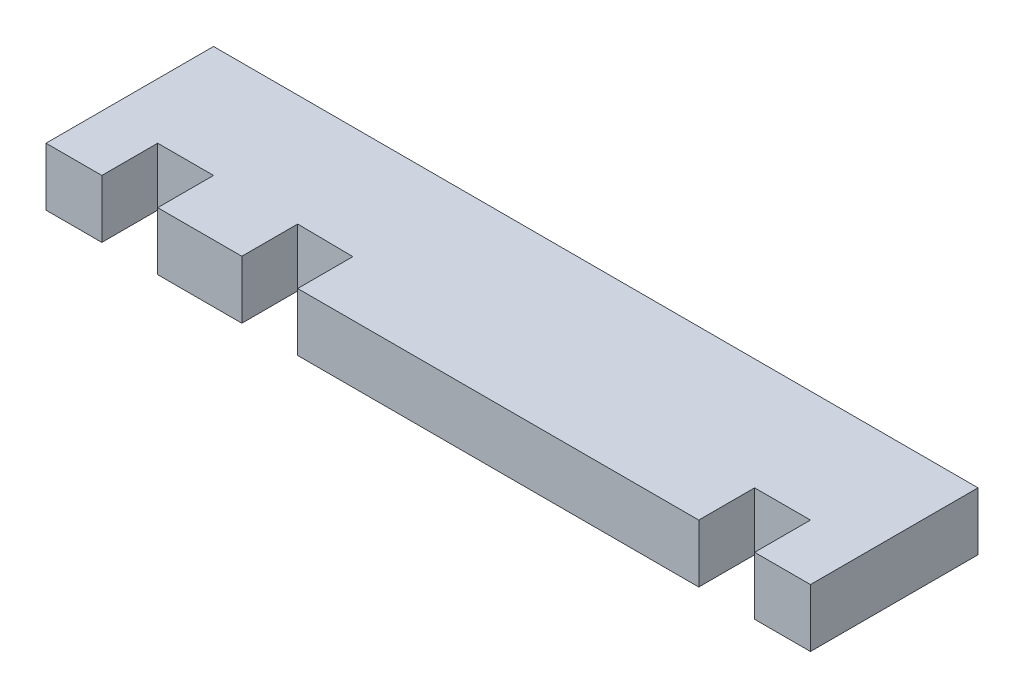
from build123d import *

# Parameters (mm, degrees)
BOSS_EXTRUDE1_DEPTH = 4


with BuildPart() as part:
    # Sketch1 → Boss-Extrude1 (new body)
    with BuildSketch(Plane(origin=(0, 0, 0), x_dir=(1, 0, 0), z_dir=(0, 1, 0))):
        Polygon((-26.35, 5.775), (26.35, 5.775), (26.35, -5.775), (22.5, -5.775), (22.5, -1.925), (18.65, -1.925), (18.65, -5.775), (-9, -5.775), (-9, -1.972485769), (-12.849707145, -1.925), (-12.849707145, -5.775), (-18.65, -5.775), (-18.65, -1.925), (-22.5, -1.925), (-22.5, -5.775), (-26.35, -5.775), align=None)
    extrude(amount=BOSS_EXTRUDE1_DEPTH)


solid = part.part
